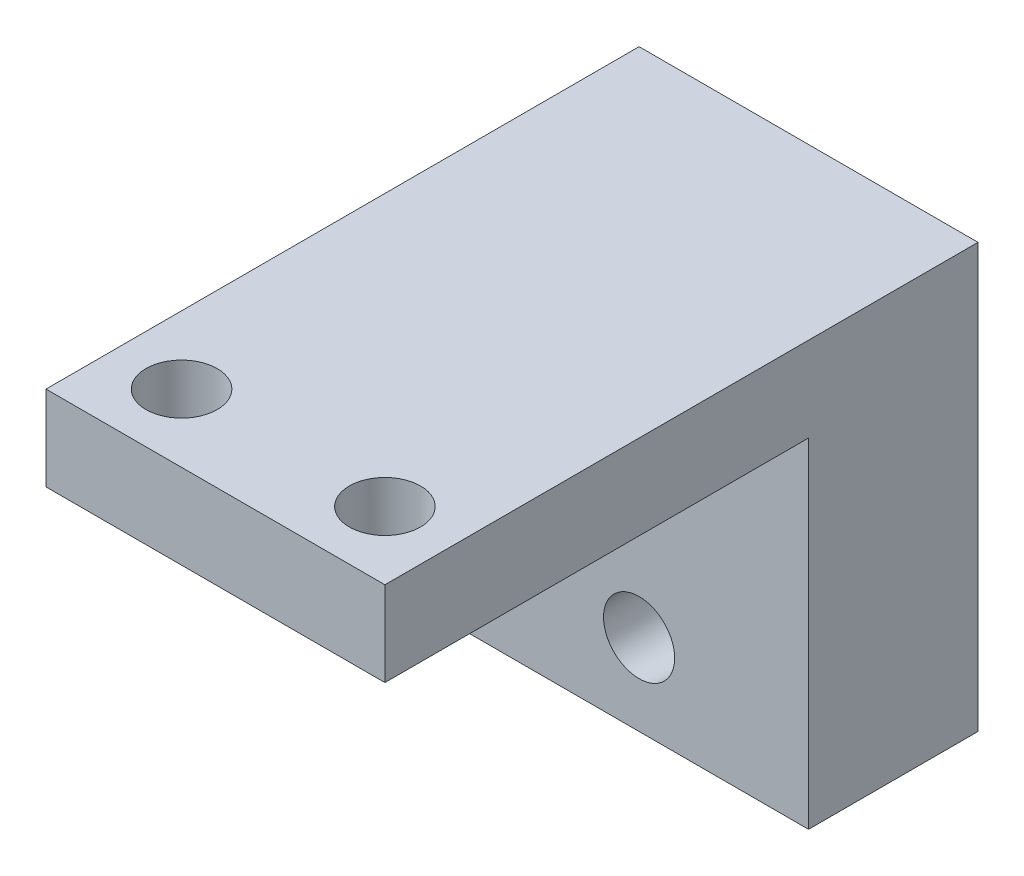
from build123d import *

# Parameters (mm, degrees)
SKETCH_1_W          = 20
SKETCH_1_H          = 20
SKETCH_1_R          = 2.1
EXTRUDE_1_DEPTH     = 10
SKETCH_2_W          = 20
SKETCH_2_H          = 10
EXTRUDE_2_DEPTH     = 5
SKETCH_3_W          = 20
SKETCH_3_H          = 5
EXTRUDE_3_DEPTH     = 25
SKETCH_4_R          = 2.1
CUT_EXTRUDE_1_DEPTH = 25


with BuildPart() as part:
    # 草图1 → 凸台-拉伸1 (new body)
    with BuildSketch(Plane.XY):
        Rectangle(SKETCH_1_W, SKETCH_1_H)
        with Locations((0, 5.2)):
            Circle(SKETCH_1_R, mode=Mode.SUBTRACT)
        with Locations((0, -5.2)):
            Circle(SKETCH_1_R, mode=Mode.SUBTRACT)
    extrude(amount=EXTRUDE_1_DEPTH)

    # 草图2 → 凸台-拉伸2 (add)
    with BuildSketch(Plane(origin=(0, 10, 0), x_dir=(1, 0, 0), z_dir=(0, 1, 0))):
        with Locations((0, -5)):
            Rectangle(SKETCH_2_W, SKETCH_2_H)
    extrude(amount=EXTRUDE_2_DEPTH)

    # 草图3 → 凸台-拉伸3 (add)
    with BuildSketch(Plane.XY.offset(10)):
        with Locations((0, 12.5)):
            Rectangle(SKETCH_3_W, SKETCH_3_H)
    extrude(amount=EXTRUDE_3_DEPTH)

    # 草图4 → 切除-拉伸1 (cut)
    with BuildSketch(Plane.XZ.offset(-10)):
        with Locations((-6, 31)):
            Circle(SKETCH_4_R)
        with Locations((6, 31)):
            Circle(SKETCH_4_R)
    extrude(amount=-CUT_EXTRUDE_1_DEPTH, mode=Mode.SUBTRACT)


solid = part.part
